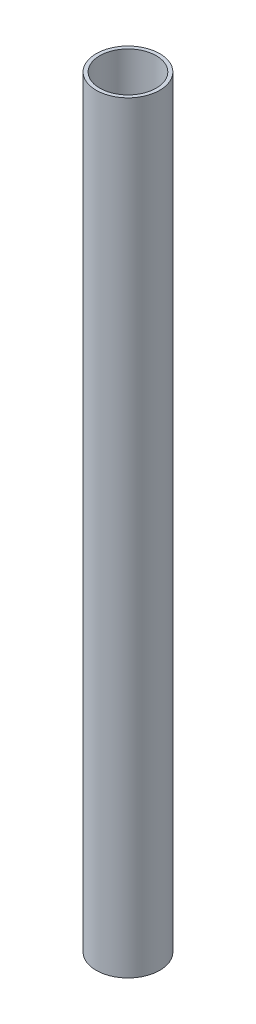
from build123d import *

# Parameters (mm, degrees)
SKETCH1_R           = 6.35
SKETCH1_R_2         = 5.6388
BOSS_EXTRUDE1_DEPTH = 152.4


with BuildPart() as part:
    # Sketch1 → Boss-Extrude1 (new body)
    with BuildSketch(Plane(origin=(0, 0, 0), x_dir=(1, 0, 0), z_dir=(0, 1, 0))):
        Circle(SKETCH1_R)
        Circle(SKETCH1_R_2, mode=Mode.SUBTRACT)
    extrude(amount=BOSS_EXTRUDE1_DEPTH)


solid = part.part
